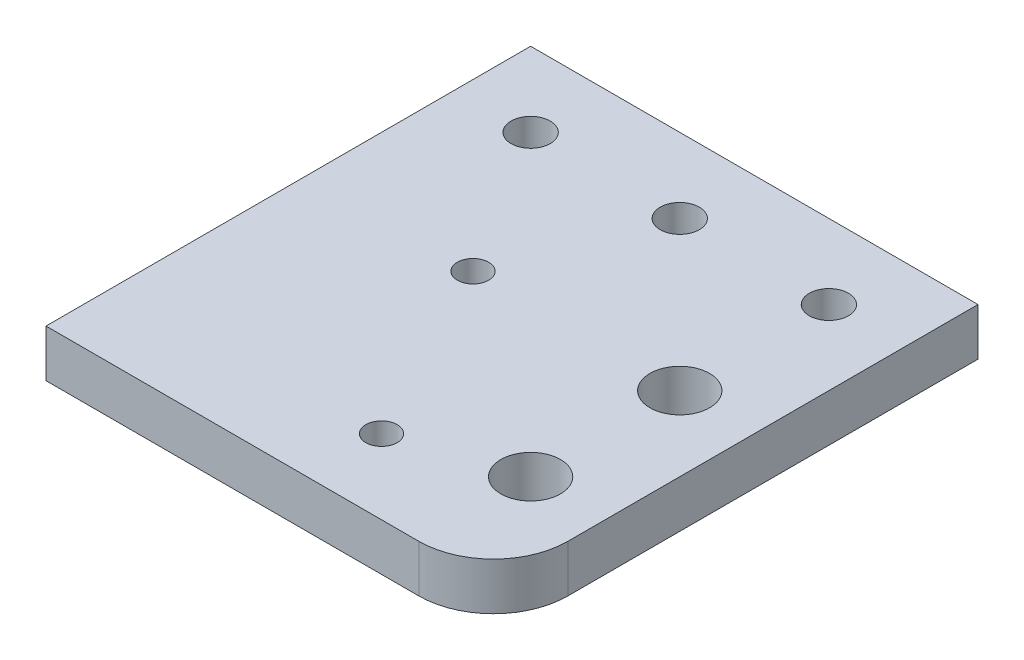
from build123d import *

# Parameters (mm, degrees)
SKETCH1_W           = 60
SKETCH1_H           = 65
SKETCH1_R           = 2.625
SKETCH1_R_2         = 2.1
BOSS_EXTRUDE1_DEPTH = 6.35
FILLET1_R           = 10
SKETCH2_R           = 4
CUT_EXTRUDE1_DEPTH  = 7.35


with BuildPart() as part:
    # Sketch1 → Boss-Extrude1 (new body)
    with BuildSketch(Plane(origin=(0, 0, 0), x_dir=(1, 0, 0), z_dir=(0, 1, 0))):
        with Locations((30, -32.5)):
            Rectangle(SKETCH1_W, SKETCH1_H)
        with Locations((10, -10)):
            Circle(SKETCH1_R, mode=Mode.SUBTRACT)
        with Locations((30, -10)):
            Circle(SKETCH1_R, mode=Mode.SUBTRACT)
        with Locations((50, -10)):
            Circle(SKETCH1_R, mode=Mode.SUBTRACT)
        with Locations((22.27, -30)):
            Circle(SKETCH1_R_2, mode=Mode.SUBTRACT)
        with Locations((35, -55)):
            Circle(SKETCH1_R_2, mode=Mode.SUBTRACT)
    extrude(amount=BOSS_EXTRUDE1_DEPTH)

    # Fillet1
    fillet1_edges = [part.edges().sort_by_distance(p)[0] for p in [
        (60, 3.175, 65),
    ]]
    fillet(fillet1_edges, radius=FILLET1_R)

    # Sketch2 → Cut-Extrude1 (cut, through all)
    with BuildSketch(Plane(origin=(0, 6.35, 0), x_dir=(1, 0, 0), z_dir=(0, 1, 0))):
        with Locations((50, -30)):
            Circle(SKETCH2_R)
        with Locations((50, -50)):
            Circle(SKETCH2_R)
    extrude(amount=-CUT_EXTRUDE1_DEPTH, mode=Mode.SUBTRACT)


solid = part.part
